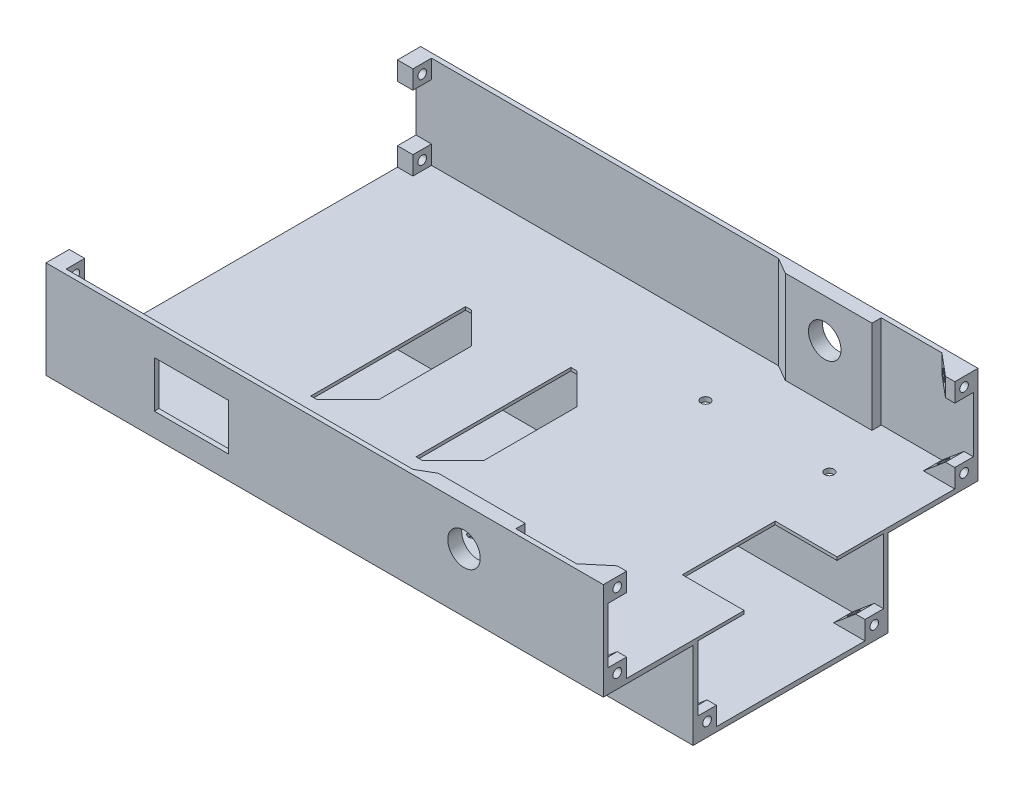
from build123d import *

# Parameters (mm, degrees)
VYSUNOUT_TENKOST_NN_1_DEPTH       = 180
SKICA5_W                          = 60
SKICA5_H                          = 1
P_IDAT_VYSUNUT_M3_DEPTH           = 180
SKICA6_W                          = 40
SKICA6_H                          = 30
ODEBRAT_VYSUNUT_M2_DEPTH          = 3
SKICA7_W                          = 6
SKICA7_H                          = 6
P_IDAT_VYSUNUT_M4_DEPTH           = 5
SKICA8_R                          = 1.4
ODEBRAT_VYSUNUT_M3_DEPTH          = 5
SKICA9_R                          = 5.25
ODEBRAT_VYSUNUT_M4_DEPTH          = 225.510578815
P_IDAT_VYSUNUT_M7_DEPTH           = 6
SKICA16_R                         = 1.4
ODEBRAT_VYSUNUT_M13_DEPTH         = 10
P_IDAT_VYSUNUT_M8_DEPTH           = 6
SKICA18_R                         = 1.4
ODEBRAT_VYSUNUT_M14_DEPTH         = 16
P_IDAT_VYSUNUT_M9_DEPTH           = 6
SKICA20_R                         = 1.4
ODEBRAT_VYSUNUT_M15_DEPTH         = 16
ODEBRAT_START                     = -25
ODEBRAT_VYSUNUT_M16_DEPTH         = 8
P_IDAT_VYSUNUT_M10_DEPTH          = 30
SKICA23_R                         = 5.25
ODEBRAT_VYSUNUT_M17_DEPTH         = 224.705721876
D_RY_PRO_KOL_K_VELIKOST_MM1_D     = 3
D_RY_PRO_KOL_K_VELIKOST_MM1_DEPTH = 10
D_RY_PRO_KOL_K_VELIKOST_MM1_TIP   = 0.901290929
SKICA29_W                         = 6
SKICA29_H                         = 3
ODEBRAT_VYSUNUT_M18_DEPTH         = 10
SKICA30_W                         = 24
SKICA30_H                         = 15
ODEBRAT_VYSUNUT_M19_DEPTH         = 5


with BuildPart() as part:
    # Skica4 → Vysunout tenkostěnný1 (new body)
    with BuildSketch(Plane(origin=(0, 0, 0), x_dir=(0, 0, -1), z_dir=(1, 0, 0))):
        Polygon((0, 0), (30, 0), (30, 28), (59, 28), (59, 58), (60.5, 58), (60.5, 26.5), (31.5, 26.5), (31.5, -1.5), (0, -1.5), align=None)
    vysunout_tenkost_nn_1 = extrude(amount=VYSUNOUT_TENKOST_NN_1_DEPTH)

    # Zrcadlit1: Vysunout tenkostěnný1 across plane
    add(vysunout_tenkost_nn_1.mirror(Plane(origin=(180, -1.5, 0), x_dir=(1, 0, 0), z_dir=(0, 0, 1))))

    # Skica5 → Přidat vysunutím3 (add)
    with BuildSketch(Plane.ZY):
        with Locations((0, 27.5)):
            Rectangle(SKICA5_W, SKICA5_H)
    extrude(amount=-P_IDAT_VYSUNUT_M3_DEPTH)

    # Skica6 → Odebrat vysunutím2 (cut)
    with BuildSketch(Plane(origin=(0, 28, 0), x_dir=(1, 0, 0), z_dir=(0, 1, 0))):
        with Locations((180, 0)):
            Rectangle(SKICA6_W, SKICA6_H)
    extrude(amount=-ODEBRAT_VYSUNUT_M2_DEPTH, mode=Mode.SUBTRACT)

    # Skica7 → Přidat vysunutím4 (add)
    with BuildSketch(Plane.ZY):
        with Locations((-56, 31)):
            Rectangle(SKICA7_W, SKICA7_H)
        with Locations((-56, 55)):
            Rectangle(SKICA7_W, SKICA7_H)
        with Locations((56, 55)):
            Rectangle(SKICA7_W, SKICA7_H)
        with Locations((56, 31)):
            Rectangle(SKICA7_W, SKICA7_H)
        with Locations((27, 3)):
            Rectangle(SKICA7_W, SKICA7_H)
        with Locations((-27, 3)):
            Rectangle(SKICA7_W, SKICA7_H)
    extrude(amount=-P_IDAT_VYSUNUT_M4_DEPTH)

    # Skica8 → Odebrat vysunutím3 (cut)
    with BuildSketch(Plane.ZY):
        with Locations((-56, 55)):
            Circle(SKICA8_R)
        with Locations((-56, 31)):
            Circle(SKICA8_R)
        with Locations((-27, 3)):
            Circle(SKICA8_R)
        with Locations((27, 3)):
            Circle(SKICA8_R)
        with Locations((56, 31)):
            Circle(SKICA8_R)
        with Locations((56, 55)):
            Circle(SKICA8_R)
    extrude(amount=-ODEBRAT_VYSUNUT_M3_DEPTH, mode=Mode.SUBTRACT)

    # Skica9 → Odebrat vysunutím4 (cut, through all)
    with BuildSketch(Plane(origin=(0, 0, -60.5), x_dir=(-1, 0, 0), z_dir=(0, 0, -1))):
        with Locations((-135, 45.5)):
            Circle(SKICA9_R)
    extrude(amount=-ODEBRAT_VYSUNUT_M4_DEPTH, mode=Mode.SUBTRACT)

    # Skica15 → Přidat vysunutím7 (add)
    with BuildSketch(Plane.XY.offset(-30)):
        Polygon((180, 0), (180, 6), (177, 6), (169.849478444, 0), align=None)
    p_idat_vysunut_m7 = extrude(amount=P_IDAT_VYSUNUT_M7_DEPTH)

    # Skica16 → Odebrat vysunutím13 (cut)
    with BuildSketch(Plane(origin=(180, 0, 0), x_dir=(0, 0, -1), z_dir=(1, 0, 0))):
        with Locations(Location((27, 3, 0), (0, 0, 180))):
            Circle(SKICA16_R)
    odebrat_vysunut_m13 = extrude(amount=-ODEBRAT_VYSUNUT_M13_DEPTH, mode=Mode.SUBTRACT)

    # Skica17 → Přidat vysunutím8 (add)
    with BuildSketch(Plane.XY.offset(-59)):
        Polygon((180, 28), (180, 34), (177, 34), (169.849478444, 28), align=None)
    p_idat_vysunut_m8 = extrude(amount=P_IDAT_VYSUNUT_M8_DEPTH)

    # Skica18 → Odebrat vysunutím14 (cut)
    with BuildSketch(Plane(origin=(180, 0, 0), x_dir=(0, 0, -1), z_dir=(1, 0, 0))):
        with Locations(Location((56, 31, 0), (0, 0, 180))):
            Circle(SKICA18_R)
    odebrat_vysunut_m14 = extrude(amount=-ODEBRAT_VYSUNUT_M14_DEPTH, mode=Mode.SUBTRACT)

    # Skica19 → Přidat vysunutím9 (add)
    with BuildSketch(Plane(origin=(0, 58, 0), x_dir=(1, 0, 0), z_dir=(0, 1, 0))):
        Polygon((180, 59), (177, 59), (169.849478444, 59), (177, 53), (180, 53), align=None)
    p_idat_vysunut_m9 = extrude(amount=-P_IDAT_VYSUNUT_M9_DEPTH)

    # Skica20 → Odebrat vysunutím15 (cut)
    with BuildSketch(Plane(origin=(180, 0, 0), x_dir=(0, 0, -1), z_dir=(1, 0, 0))):
        with Locations(Location((56, 55, 0), (0, 0, 180))):
            Circle(SKICA20_R)
    odebrat_vysunut_m15 = extrude(amount=-ODEBRAT_VYSUNUT_M15_DEPTH, mode=Mode.SUBTRACT)

    # Zrcadlit2: Přidat vysunutím7, Odebrat vysunutím13, Přidat vysunutím8, Odebrat vysunutím14, Přidat vysunutím9, Odebrat vysunutím15 across plane
    add(p_idat_vysunut_m7.mirror(Plane.XY))
    add(odebrat_vysunut_m13.mirror(Plane.XY), mode=Mode.SUBTRACT)
    add(p_idat_vysunut_m8.mirror(Plane.XY))
    add(odebrat_vysunut_m14.mirror(Plane.XY), mode=Mode.SUBTRACT)
    add(p_idat_vysunut_m9.mirror(Plane.XY))
    add(odebrat_vysunut_m15.mirror(Plane.XY), mode=Mode.SUBTRACT)

    # Skica21 → Odebrat vysunutím16 (cut)
    with BuildSketch(Plane.XZ.offset(1.5).offset(ODEBRAT_START)):
        Polygon((62, -15), (52, -25), (50, -25), (50, 25), (52, 25), (62, 15), align=None)
        Polygon((86, -25), (84, -25), (84, 25), (86, 25), (96, 15), (96, -15), align=None)
    extrude(amount=-ODEBRAT_VYSUNUT_M16_DEPTH, mode=Mode.SUBTRACT)

    # Skica22 → Přidat vysunutím10 (add)
    with BuildSketch(Plane(origin=(0, 28, 0), x_dir=(1, 0, 0), z_dir=(0, 1, 0))):
        Polygon((117.053847577, 59), (150.25, 59), (150.25, 56), (122.25, 56), align=None)
        Polygon((122.25, -56), (117.053847577, -59), (150.25, -59), (150.25, -56), align=None)
    extrude(amount=P_IDAT_VYSUNUT_M10_DEPTH)

    # Skica23 → Odebrat vysunutím17 (cut, through all)
    with BuildSketch(Plane.XY.offset(59)):
        with Locations(Location((135, 45.5, 0), (0, 0, 180))):
            Circle(SKICA23_R)
    extrude(amount=-ODEBRAT_VYSUNUT_M17_DEPTH, mode=Mode.SUBTRACT)

    # Díry pro kolík, velikost mm1
    with Locations(Plane(origin=(0, 28, 0), x_dir=(1, 0, 0), z_dir=(0, 1, 0))):
        with Locations((155, -37.5), (115, -37.5), (115, 37.5), (155, 37.5)):
            Hole(D_RY_PRO_KOL_K_VELIKOST_MM1_D / 2, depth=D_RY_PRO_KOL_K_VELIKOST_MM1_DEPTH)
            with Locations((0, 0, -(D_RY_PRO_KOL_K_VELIKOST_MM1_DEPTH + D_RY_PRO_KOL_K_VELIKOST_MM1_TIP / 2))):  # 118° drill point
                Cone(0, D_RY_PRO_KOL_K_VELIKOST_MM1_D / 2, D_RY_PRO_KOL_K_VELIKOST_MM1_TIP, mode=Mode.SUBTRACT)

    # Skica29 → Odebrat vysunutím18 (cut)
    with BuildSketch(Plane.XY.offset(31.5)):
        with Locations((23, 10)):
            Rectangle(SKICA29_W, SKICA29_H)
    extrude(amount=-ODEBRAT_VYSUNUT_M18_DEPTH, mode=Mode.SUBTRACT)

    # Skica30 → Odebrat vysunutím19 (cut)
    with BuildSketch(Plane.XY.offset(60.5)):
        with Locations((47, 41.5)):
            Rectangle(SKICA30_W, SKICA30_H)
    extrude(amount=-ODEBRAT_VYSUNUT_M19_DEPTH, mode=Mode.SUBTRACT)


solid = part.part
